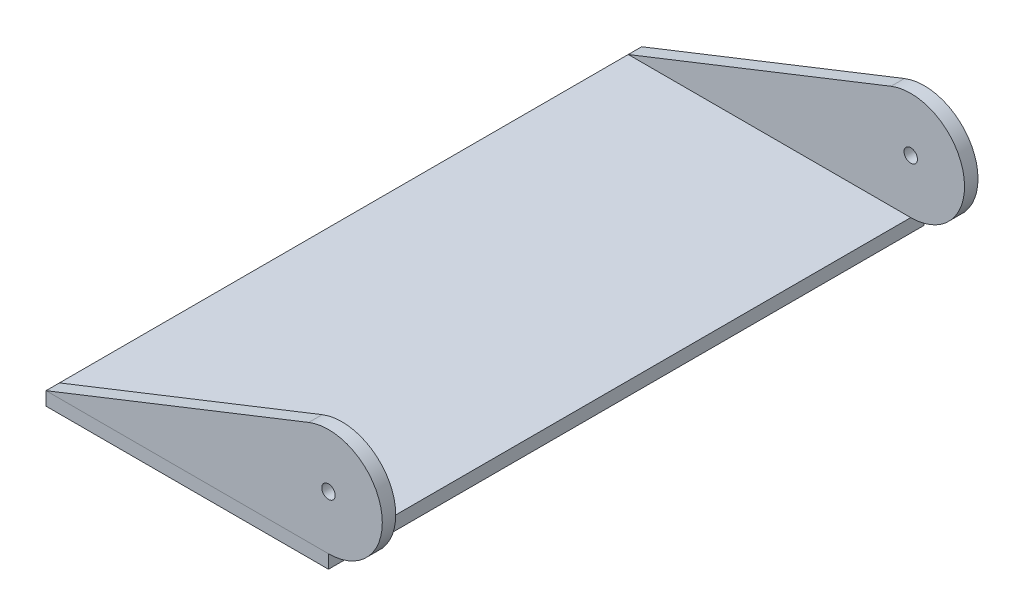
from build123d import *

# Parameters (mm, degrees)
SKETCH1_W           = 33.3375
SKETCH1_H           = 70.3
BOSS_EXTRUDE1_DEPTH = 1.5875
SKETCH3_R           = 0.79375
BOSS_EXTRUDE2_DEPTH = 70.3
SKETCH4_W           = 67.125
SKETCH4_H           = 12.7
CUT_EXTRUDE1_DEPTH  = 40.6875


with BuildPart() as part:
    # Sketch1 → Boss-Extrude1 (new body)
    with BuildSketch(Plane(origin=(0, 0, 0), x_dir=(1, 0, 0), z_dir=(0, 1, 0))):
        with Locations((16.252975171, -34.625224743)):
            Rectangle(SKETCH1_W, SKETCH1_H)
    extrude(amount=BOSS_EXTRUDE1_DEPTH)


with BuildPart() as body_2:
    # Sketch3 → Boss-Extrude2 (new body)
    with BuildSketch(Plane.XY.offset(69.775224743)):
        with BuildLine():
            Line((30.587370685, 13.84286105), (-0.415774829, 1.5875))
            Line((-0.415774829, 1.5875), (32.921725171, 1.5875))
            ThreePointArc((32.921725171, 1.5875), (39.159575068, 9.125661885), (30.587370685, 13.84286105))
        make_face()
        with Locations((32.921725171, 7.9375)):
            Circle(SKETCH3_R, mode=Mode.SUBTRACT)
    extrude(amount=-BOSS_EXTRUDE2_DEPTH)

    # Sketch4 → Cut-Extrude1 (cut, through all)
    with BuildSketch(Plane.ZY.offset(0.415774829)):
        with Locations((34.625224743, 7.9375)):
            Rectangle(SKETCH4_W, SKETCH4_H)
    extrude(amount=-CUT_EXTRUDE1_DEPTH, mode=Mode.SUBTRACT)


solid = Compound([part.part, body_2.part])
